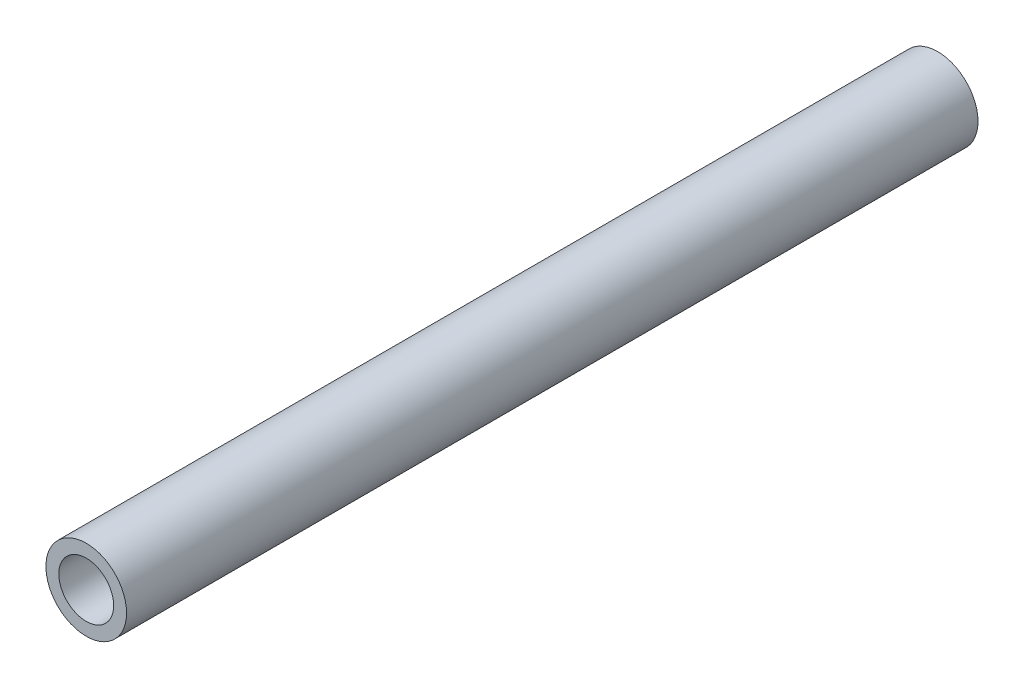
from build123d import *

# Parameters (mm, degrees)
SKETCH3_R           = 6.25
SKETCH3_R_2         = 4.25
BOSS_EXTRUDE2_DEPTH = 132


with BuildPart() as part:
    # Sketch3 → Boss-Extrude2 (new body)
    with BuildSketch(Plane.XY):
        with Locations((-29.599769725, 13.863270102)):
            Circle(SKETCH3_R)
        with Locations((-29.599769725, 13.863270102)):
            Circle(SKETCH3_R_2, mode=Mode.SUBTRACT)
    extrude(amount=BOSS_EXTRUDE2_DEPTH)


solid = part.part
